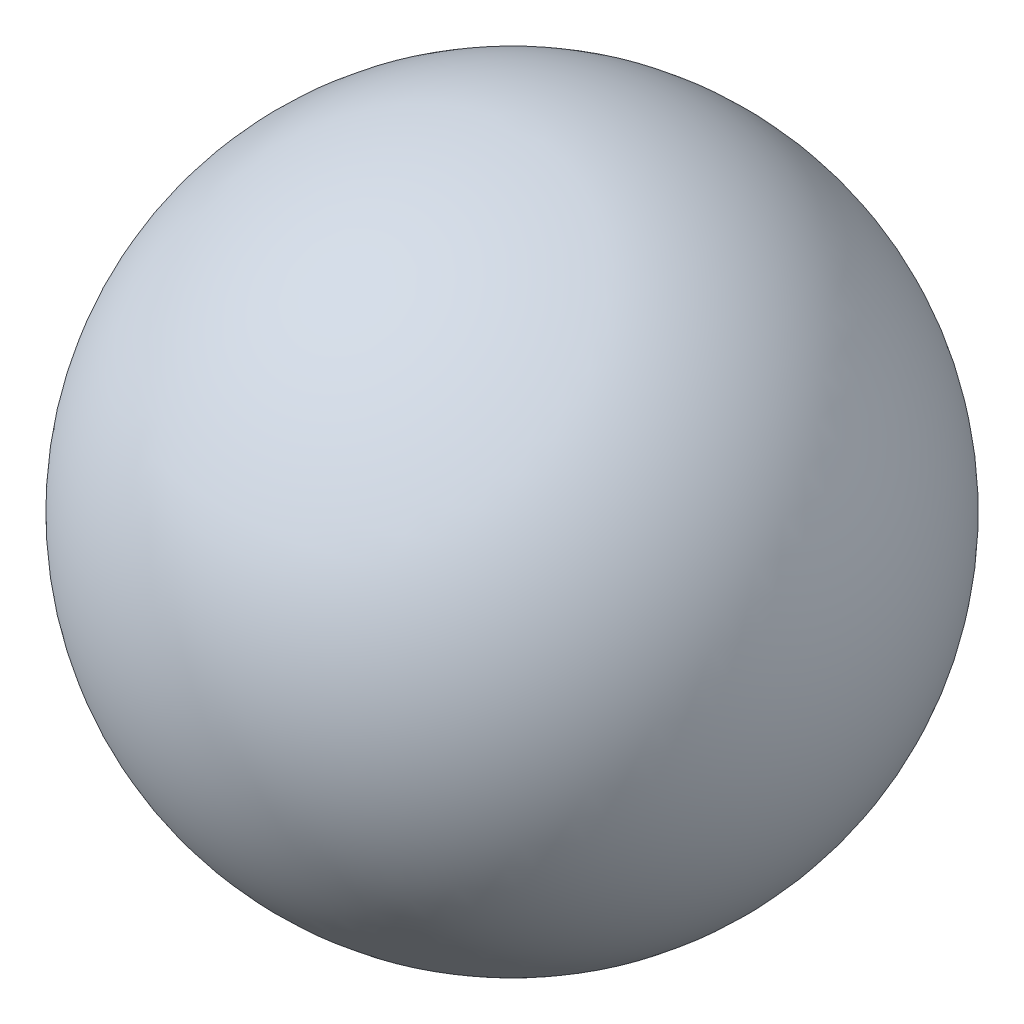
from build123d import *


with BuildPart() as part:
    # 草图1 → 旋转1 (revolve)
    with BuildSketch(Plane.XY):
        with BuildLine():
            Line((0, 2.5), (0, -2.5))
            ThreePointArc((0, -2.5), (2.5, 0), (0, 2.5))
        make_face()
    revolve(axis=Axis((0, 2.5, 0), (0, -1, 0)))


solid = part.part
